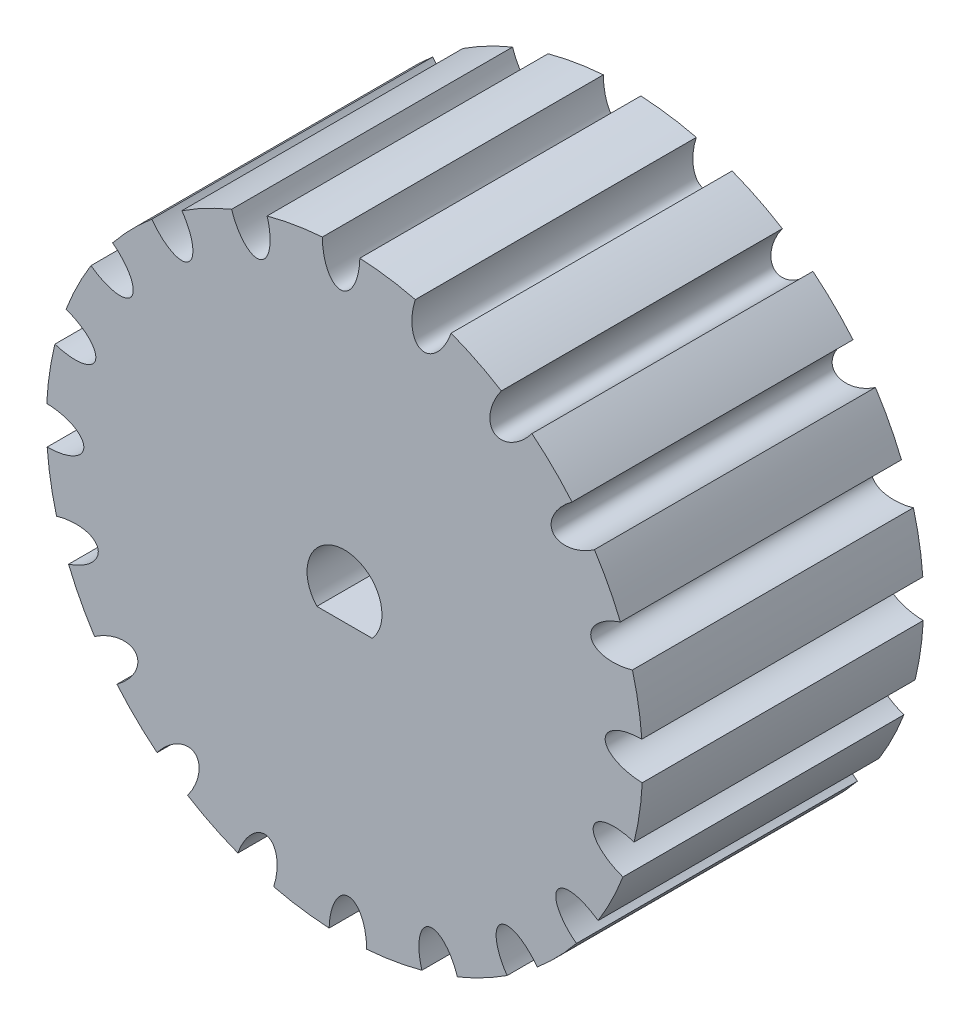
from build123d import *

# Parameters (mm, degrees)
SKETCH_1_R               = 15.91549431
EXTRUDE_1_DEPTH          = 15
CUT_EXTRUDE_1_DEPTH      = 15
SKETCH_3_RX              = 2
SKETCH_3_RY              = 1
CUT_EXTRUDE_2_DEPTH      = 15
PATTERN_CIRCULAR_1_COUNT = 20


with BuildPart() as part:
    # Эскиз1 → Бобышка-Вытянуть1 (new body)
    with BuildSketch(Plane.XY):
        Circle(SKETCH_1_R)
    extrude(amount=EXTRUDE_1_DEPTH)

    # Эскиз2 → Вырез-Вытянуть1 (cut)
    with BuildSketch(Plane.XY.offset(15)):
        with BuildLine():
            Line((-1.475635456, -1.35), (1.475635456, -1.35))
            ThreePointArc((1.475635456, -1.35), (0, 2), (-1.475635456, -1.35))
        make_face()
    extrude(amount=-CUT_EXTRUDE_1_DEPTH, mode=Mode.SUBTRACT)

    # Эскиз3 → Вырез-Вытянуть2 (cut)
    with BuildSketch(Plane.XY.offset(15)):
        with Locations(Location((12.768681862, 9.500722217), (0, 0, 34.851328061))):
            Ellipse(SKETCH_3_RX, SKETCH_3_RY)
    cut_extrude_2 = extrude(amount=-CUT_EXTRUDE_2_DEPTH, mode=Mode.SUBTRACT)

    # Круговой массив1: Вырез-Вытянуть2 ×20 about axis
    pattern_circular_1_axis = Axis((0, 0, 15), (0, 0, 1))
    for i in range(1, PATTERN_CIRCULAR_1_COUNT):
        add(cut_extrude_2.rotate(pattern_circular_1_axis, i * 360 / PATTERN_CIRCULAR_1_COUNT), mode=Mode.SUBTRACT)


solid = part.part
